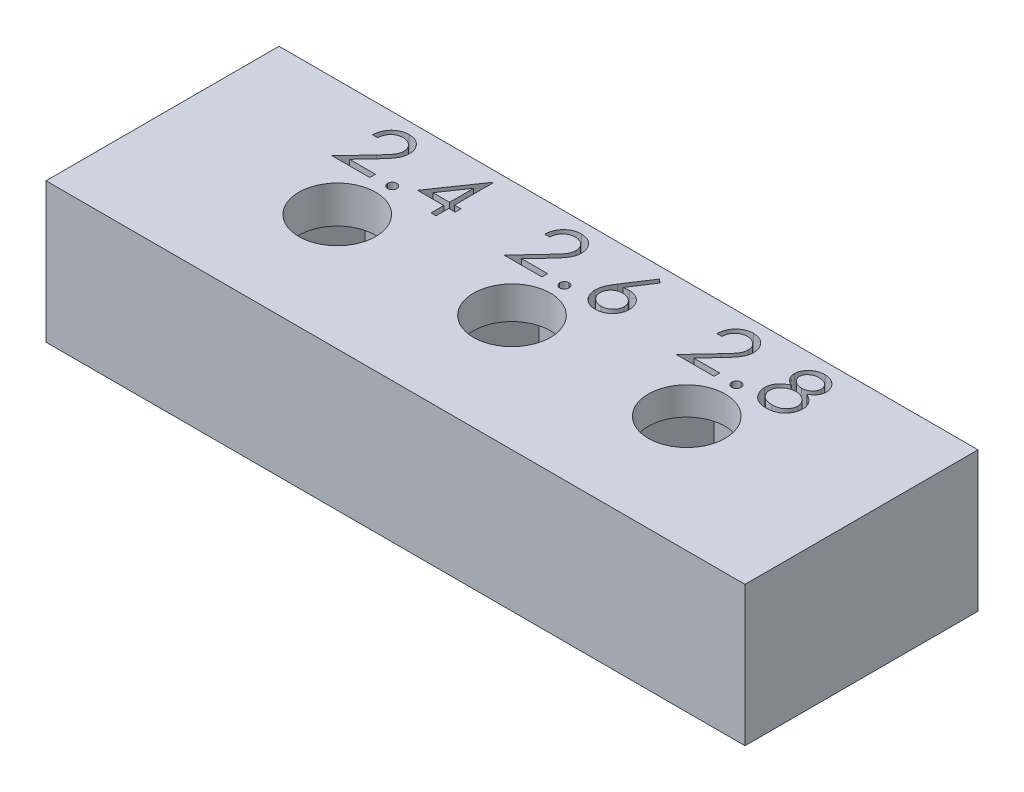
from build123d import *

# Parameters (mm, degrees)
SKETCH1_W           = 30
SKETCH1_H           = 10
SKETCH1_R           = 1.65
BOSS_EXTRUDE1_DEPTH = 6
CUT_EXTRUDE1_START  = 2
CUT_EXTRUDE1_DEPTH  = 2.4
CUT_EXTRUDE2_START  = 2
CUT_EXTRUDE2_DEPTH  = 2.6
CUT_EXTRUDE3_START  = 2
CUT_EXTRUDE3_DEPTH  = 2.8
CUT_EXTRUDE4_DEPTH  = 1


with BuildPart() as part:
    # Sketch1 → Boss-Extrude1 (new body)
    with BuildSketch(Plane(origin=(0, 0, 0), x_dir=(1, 0, 0), z_dir=(0, 1, 0))):
        with Locations((15, 5)):
            Rectangle(SKETCH1_W, SKETCH1_H)
        with Locations(Location((7.5, 5, 0), (0, 0, 270))):
            Circle(SKETCH1_R, mode=Mode.SUBTRACT)
        with Locations(Location((15, 5, 0), (0, 0, 270))):
            Circle(SKETCH1_R, mode=Mode.SUBTRACT)
        with Locations(Location((22.5, 5, 0), (0, 0, 270))):
            Circle(SKETCH1_R, mode=Mode.SUBTRACT)
    extrude(amount=BOSS_EXTRUDE1_DEPTH)

    # Sketch2 → Cut-Extrude1 (cut)
    with BuildSketch(Plane(origin=(0, 0, 0), x_dir=(1, 0, 0), z_dir=(0, 1, 0)).offset(CUT_EXTRUDE1_START)):
        Polygon((10.733161507, 5), (9.116580754, 7.8), (5.883419246, 7.8), (4.266838493, 5), (5.883419246, 2.2), (9.116580754, 2.2), align=None)
    extrude(amount=CUT_EXTRUDE1_DEPTH, mode=Mode.SUBTRACT)

    # Sketch3 → Cut-Extrude2 (cut)
    with BuildSketch(Plane(origin=(0, 0, 0), x_dir=(1, 0, 0), z_dir=(0, 1, 0)).offset(CUT_EXTRUDE2_START)):
        Polygon((18.175426481, 5), (16.58771324, 7.75), (13.41228676, 7.75), (11.824573519, 5), (13.41228676, 2.25), (16.58771324, 2.25), align=None)
    extrude(amount=CUT_EXTRUDE2_DEPTH, mode=Mode.SUBTRACT)

    # Sketch4 → Cut-Extrude3 (cut)
    with BuildSketch(Plane(origin=(0, 0, 0), x_dir=(1, 0, 0), z_dir=(0, 1, 0)).offset(CUT_EXTRUDE3_START)):
        Polygon((25.675426481, 5), (24.08771324, 7.75), (20.91228676, 7.75), (19.324573519, 5), (20.91228676, 2.25), (24.08771324, 2.25), align=None)
    extrude(amount=CUT_EXTRUDE3_DEPTH, mode=Mode.SUBTRACT)

    # Sketch5 → Cut-Extrude4 (cut)
    with BuildSketch(Plane(origin=(0, 6, 0), x_dir=(1, 0, 0), z_dir=(0, 1, 0))):
        with BuildLine():
            Line((5.513180713, 8.716214806), (5.29947879, 8.716214806))
            add(Edge.make_bspline(
                [(5.29947879, 8.716214806), (5.300871585, 8.744565892), (5.303606997, 8.800246671), (5.316416958, 8.881429543), (5.334746377, 8.95902754), (5.36066217, 9.032417606), (5.392847334, 9.102248652), (5.431444013, 9.168243305), (5.477159829, 9.23014981), (5.529007625, 9.287394274), (5.58531986, 9.339909389), (5.646079793, 9.385258759), (5.709927928, 9.423574889), (5.776670555, 9.455606948), (5.847060688, 9.479650665), (5.920459561, 9.497490745), (5.997189652, 9.508224294), (6.04946831, 9.509378034), (6.076056314, 9.509964806)],
                knots=[0, 0, 0, 0, 1.10065271, 2.161652631, 3.183658789, 4.190468796, 5.17591951, 6.163126047, 7.15150782, 8.156236427, 9.156009102, 10.134482811, 11.092018607, 12.041330605, 13.001268258, 13.972401359, 14.968799086, 16, 16, 16, 16], degree=3))
            add(Edge.make_bspline(
                [(6.076056314, 9.509964806), (6.10216711, 9.509353535), (6.153473893, 9.508152408), (6.228355371, 9.497837494), (6.299641352, 9.481682011), (6.367192493, 9.459015629), (6.430469833, 9.428546224), (6.489948726, 9.391944685), (6.546337278, 9.349612978), (6.597096536, 9.299774223), (6.643706497, 9.246568672), (6.683917138, 9.18976708), (6.718352166, 9.13110037), (6.747054855, 9.070121183), (6.768184121, 9.006255358), (6.784225723, 8.940432708), (6.793293124, 8.871971899), (6.794684743, 8.825635117), (6.795392251, 8.802077186)],
                knots=[0, 0, 0, 0, 1.111607364, 2.184268762, 3.212621178, 4.221274766, 5.211760367, 6.196651075, 7.1921475, 8.207485113, 9.220403448, 10.201281604, 11.166441695, 12.114753415, 13.065576456, 14.026450734, 14.996634279, 16, 16, 16, 16], degree=3))
            add(Edge.make_bspline(
                [(6.795392251, 8.802077186), (6.794240228, 8.768911248), (6.791956397, 8.703161389), (6.772420366, 8.606540562), (6.741908722, 8.512927897), (6.705171234, 8.437586982), (6.668110518, 8.376876337), (6.634713481, 8.326891379), (6.595616887, 8.273071409), (6.550251694, 8.215596649), (6.49955633, 8.154016908), (6.443071608, 8.088369387), (6.380394739, 8.019332343), (6.336403866, 7.972179782), (6.313608898, 7.947746507)],
                knots=[0, 0, 0, 0, 1.184426356, 2.348067706, 3.509069118, 4.696110526, 5.333549288, 6.050745305, 6.844228056, 7.710549037, 8.667450064, 9.695053472, 10.805634456, 12, 12, 12, 12], degree=3))
            Line((6.313608898, 7.947746507), (5.717819385, 7.311887883))
            Line((5.717819385, 7.311887883), (6.825921097, 7.311887883))
            Line((6.825921097, 7.311887883), (6.825921097, 7.067657114))
            Line((6.825921097, 7.067657114), (5.207892251, 7.067657114))
            Line((5.207892251, 7.067657114), (6.131389847, 8.053166428))
            add(Edge.make_bspline(
                [(6.131389847, 8.053166428), (6.153874213, 8.076637598), (6.197062078, 8.12172091), (6.258146296, 8.187540674), (6.313009607, 8.248602415), (6.362007155, 8.304790764), (6.404076022, 8.356927598), (6.441408737, 8.403324352), (6.471321041, 8.44601979), (6.503784551, 8.495509387), (6.535226564, 8.555933481), (6.562245149, 8.629775152), (6.578719894, 8.705789586), (6.580696219, 8.757157936), (6.581690328, 8.782996657)],
                knots=[0, 0, 0, 0, 1.329631726, 2.553950428, 3.673215718, 4.687767853, 5.603093632, 6.413772471, 7.123043292, 7.734684054, 8.834405432, 9.900288307, 10.943827018, 12, 12, 12, 12], degree=3))
            add(Edge.make_bspline(
                [(6.581690328, 8.782996657), (6.581257796, 8.799244537), (6.580405359, 8.831265988), (6.572882176, 8.878214549), (6.561513063, 8.923502396), (6.545221736, 8.967268831), (6.523717865, 9.00907382), (6.497542226, 9.048968248), (6.467341129, 9.08753699), (6.432403926, 9.123700216), (6.394023946, 9.156820822), (6.353478572, 9.186160602), (6.310581984, 9.210680068), (6.265515043, 9.230780198), (6.218403394, 9.246547734), (6.169155915, 9.257473303), (6.117908683, 9.264332993), (6.082915537, 9.265261117), (6.06508501, 9.265734037)],
                knots=[0, 0, 0, 0, 0.991446411, 1.95395049, 2.89581595, 3.838931463, 4.798493298, 5.75982156, 6.748411868, 7.785213223, 8.824556874, 9.840280684, 10.836137867, 11.835679398, 12.848801643, 13.863922112, 14.911575587, 16, 16, 16, 16], degree=3))
            add(Edge.make_bspline(
                [(6.06508501, 9.265734037), (6.046463068, 9.265247559), (6.009892649, 9.264292198), (5.956199522, 9.257609279), (5.904978305, 9.246080055), (5.856100153, 9.230311639), (5.809482364, 9.210269305), (5.765351648, 9.185305814), (5.723807075, 9.155517402), (5.684770548, 9.121744095), (5.648804162, 9.084142388), (5.617203698, 9.042225609), (5.589592074, 8.9967591), (5.565501149, 8.94786554), (5.54593701, 8.895101271), (5.53098742, 8.838653601), (5.519158155, 8.778767625), (5.515206287, 8.737412059), (5.513180713, 8.716214806)],
                knots=[0, 0, 0, 0, 1.031018746, 2.02475058, 2.990194455, 3.934040569, 4.864654155, 5.795059489, 6.735614925, 7.690564532, 8.649604399, 9.611025574, 10.590972636, 11.591080095, 12.624614302, 13.701020113, 14.821632451, 16, 16, 16, 16], degree=3))
        make_face()
        with BuildLine():
            add(Edge.make_bspline(
                [(7.622723982, 7.434003267), (7.635984287, 7.4332153), (7.661979565, 7.431670583), (7.6995619, 7.421072882), (7.733576124, 7.402255115), (7.763873955, 7.37717526), (7.788847468, 7.346766247), (7.808335858, 7.313023316), (7.818841243, 7.275126339), (7.820374708, 7.248980436), (7.821161482, 7.235565767)],
                knots=[0, 0, 0, 0, 1.020151414, 1.999887582, 2.974338812, 3.990962822, 5.007586832, 5.987933904, 6.967670073, 8, 8, 8, 8], degree=3))
            add(Edge.make_bspline(
                [(7.821161482, 7.235565767), (7.820348046, 7.222473431), (7.818743963, 7.196655535), (7.808359939, 7.159044397), (7.788698944, 7.125280378), (7.764046208, 7.094458744), (7.733568634, 7.069325759), (7.699481485, 7.050668091), (7.66206779, 7.039311583), (7.635999006, 7.037864942), (7.622723982, 7.037128267)],
                knots=[0, 0, 0, 0, 1.009421747, 1.99056486, 2.972319754, 3.999869655, 5.017953583, 5.993804169, 6.978383603, 8, 8, 8, 8], degree=3))
            add(Edge.make_bspline(
                [(7.622723982, 7.037128267), (7.609439392, 7.037838286), (7.583504394, 7.039224429), (7.546230352, 7.050901267), (7.511935611, 7.069150799), (7.481463971, 7.094505608), (7.456604761, 7.125121777), (7.437809634, 7.159276927), (7.426522408, 7.19654787), (7.425037955, 7.222452225), (7.424286482, 7.235565767)],
                knots=[0, 0, 0, 0, 1.022052826, 1.995314843, 2.982371812, 4.00089066, 5.028879526, 6.005146991, 6.990147033, 8, 8, 8, 8], degree=3))
            add(Edge.make_bspline(
                [(7.424286482, 7.235565767), (7.425009089, 7.249002399), (7.42641989, 7.275235773), (7.43783333, 7.31279088), (7.456458931, 7.346923336), (7.481635816, 7.377128866), (7.511928239, 7.402429513), (7.546147621, 7.420843239), (7.583594166, 7.431756448), (7.609454499, 7.433241339), (7.622723982, 7.434003267)],
                knots=[0, 0, 0, 0, 1.032775665, 2.016367738, 2.991239715, 4.008302682, 5.025365648, 6.011011707, 6.979408107, 8, 8, 8, 8], degree=3))
        make_face()
        Polygon((9.627801356, 9.509964806), (9.671209559, 9.509964806), (9.671209559, 7.861407114), (9.945969174, 7.861407114), (9.945969174, 7.617176344), (9.671209559, 7.617176344), (9.671209559, 7.067657114), (9.457507636, 7.067657114), (9.457507636, 7.617176344), (8.327940328, 7.617176344), align=None)
        Polygon((9.457507636, 7.861407114), (9.457507636, 8.895571777), (8.747711963, 7.861407114), align=None, mode=Mode.SUBTRACT)
        with BuildLine():
            Line((12.901161482, 8.716214806), (12.687459559, 8.716214806))
            add(Edge.make_bspline(
                [(12.687459559, 8.716214806), (12.688852354, 8.744565892), (12.691587767, 8.800246671), (12.704397728, 8.881429543), (12.722727146, 8.95902754), (12.748642939, 9.032417606), (12.780828103, 9.102248652), (12.819424782, 9.168243305), (12.865140598, 9.23014981), (12.916988394, 9.287394274), (12.973300629, 9.339909389), (13.034060563, 9.385258759), (13.097908697, 9.423574889), (13.164651324, 9.455606948), (13.235041458, 9.479650665), (13.30844033, 9.497490745), (13.385170421, 9.508224294), (13.437449079, 9.509378034), (13.464037083, 9.509964806)],
                knots=[0, 0, 0, 0, 1.10065271, 2.161652631, 3.183658789, 4.190468796, 5.17591951, 6.163126047, 7.15150782, 8.156236427, 9.156009102, 10.134482811, 11.092018607, 12.041330605, 13.001268258, 13.972401359, 14.968799086, 16, 16, 16, 16], degree=3))
            add(Edge.make_bspline(
                [(13.464037083, 9.509964806), (13.49014788, 9.509353535), (13.541454663, 9.508152408), (13.61633614, 9.497837494), (13.687622121, 9.481682011), (13.755173262, 9.459015629), (13.818450603, 9.428546224), (13.877929495, 9.391944685), (13.934318047, 9.349612978), (13.985077305, 9.299774223), (14.031687266, 9.246568672), (14.071897908, 9.18976708), (14.106332935, 9.13110037), (14.135035624, 9.070121183), (14.15616489, 9.006255358), (14.172206493, 8.940432708), (14.181273894, 8.871971899), (14.182665512, 8.825635117), (14.18337302, 8.802077186)],
                knots=[0, 0, 0, 0, 1.111607364, 2.184268762, 3.212621178, 4.221274766, 5.211760367, 6.196651075, 7.1921475, 8.207485113, 9.220403448, 10.201281604, 11.166441695, 12.114753415, 13.065576456, 14.026450734, 14.996634279, 16, 16, 16, 16], degree=3))
            add(Edge.make_bspline(
                [(14.18337302, 8.802077186), (14.182220997, 8.768911248), (14.179937166, 8.703161389), (14.160401135, 8.606540562), (14.129889491, 8.512927897), (14.093152003, 8.437586982), (14.056091287, 8.376876337), (14.022694251, 8.326891379), (13.983597656, 8.273071409), (13.938232464, 8.215596649), (13.887537099, 8.154016908), (13.831052377, 8.088369387), (13.768375508, 8.019332343), (13.724384635, 7.972179782), (13.701589667, 7.947746507)],
                knots=[0, 0, 0, 0, 1.184426356, 2.348067706, 3.509069118, 4.696110526, 5.333549288, 6.050745305, 6.844228056, 7.710549037, 8.667450064, 9.695053472, 10.805634456, 12, 12, 12, 12], degree=3))
            Line((13.701589667, 7.947746507), (13.105800154, 7.311887883))
            Line((13.105800154, 7.311887883), (14.213901866, 7.311887883))
            Line((14.213901866, 7.311887883), (14.213901866, 7.067657114))
            Line((14.213901866, 7.067657114), (12.59587302, 7.067657114))
            Line((12.59587302, 7.067657114), (13.519370616, 8.053166428))
            add(Edge.make_bspline(
                [(13.519370616, 8.053166428), (13.541854982, 8.076637598), (13.585042848, 8.12172091), (13.646127065, 8.187540674), (13.700990377, 8.248602415), (13.749987924, 8.304790764), (13.792056791, 8.356927598), (13.829389506, 8.403324352), (13.85930181, 8.44601979), (13.89176532, 8.495509387), (13.923207333, 8.555933481), (13.950225918, 8.629775152), (13.966700663, 8.705789586), (13.968676989, 8.757157936), (13.969671097, 8.782996657)],
                knots=[0, 0, 0, 0, 1.329631726, 2.553950428, 3.673215718, 4.687767853, 5.603093632, 6.413772471, 7.123043292, 7.734684054, 8.834405432, 9.900288307, 10.943827018, 12, 12, 12, 12], degree=3))
            add(Edge.make_bspline(
                [(13.969671097, 8.782996657), (13.969238565, 8.799244537), (13.968386128, 8.831265988), (13.960862945, 8.878214549), (13.949493833, 8.923502396), (13.933202505, 8.967268831), (13.911698634, 9.00907382), (13.885522995, 9.048968248), (13.855321898, 9.08753699), (13.820384695, 9.123700216), (13.782004715, 9.156820822), (13.741459342, 9.186160602), (13.698562753, 9.210680068), (13.653495813, 9.230780198), (13.606384163, 9.246547734), (13.557136684, 9.257473303), (13.505889452, 9.264332993), (13.470896306, 9.265261117), (13.453065779, 9.265734037)],
                knots=[0, 0, 0, 0, 0.991446411, 1.95395049, 2.89581595, 3.838931463, 4.798493298, 5.75982156, 6.748411868, 7.785213223, 8.824556874, 9.840280684, 10.836137867, 11.835679398, 12.848801643, 13.863922112, 14.911575587, 16, 16, 16, 16], degree=3))
            add(Edge.make_bspline(
                [(13.453065779, 9.265734037), (13.434443837, 9.265247559), (13.397873419, 9.264292198), (13.344180291, 9.257609279), (13.292959074, 9.246080055), (13.244080923, 9.230311639), (13.197463133, 9.210269305), (13.153332417, 9.185305814), (13.111787844, 9.155517402), (13.072751317, 9.121744095), (13.036784931, 9.084142388), (13.005184467, 9.042225609), (12.977572843, 8.9967591), (12.953481919, 8.94786554), (12.933917779, 8.895101271), (12.91896819, 8.838653601), (12.907138924, 8.778767625), (12.903187056, 8.737412059), (12.901161482, 8.716214806)],
                knots=[0, 0, 0, 0, 1.031018746, 2.02475058, 2.990194455, 3.934040569, 4.864654155, 5.795059489, 6.735614925, 7.690564532, 8.649604399, 9.611025574, 10.590972636, 11.591080095, 12.624614302, 13.701020113, 14.821632451, 16, 16, 16, 16], degree=3))
        make_face()
        with BuildLine():
            add(Edge.make_bspline(
                [(15.010704751, 7.434003267), (15.023965056, 7.4332153), (15.049960334, 7.431670583), (15.08754267, 7.421072882), (15.121556893, 7.402255115), (15.151854724, 7.37717526), (15.176828238, 7.346766247), (15.196316627, 7.313023316), (15.206822012, 7.275126339), (15.208355477, 7.248980436), (15.209142251, 7.235565767)],
                knots=[0, 0, 0, 0, 1.020151414, 1.999887582, 2.974338812, 3.990962822, 5.007586832, 5.987933904, 6.967670073, 8, 8, 8, 8], degree=3))
            add(Edge.make_bspline(
                [(15.209142251, 7.235565767), (15.208328816, 7.222473431), (15.206724733, 7.196655535), (15.196340708, 7.159044397), (15.176679713, 7.125280378), (15.152026977, 7.094458744), (15.121549404, 7.069325759), (15.087462254, 7.050668091), (15.050048559, 7.039311583), (15.023979775, 7.037864942), (15.010704751, 7.037128267)],
                knots=[0, 0, 0, 0, 1.009421747, 1.99056486, 2.972319754, 3.999869655, 5.017953583, 5.993804169, 6.978383603, 8, 8, 8, 8], degree=3))
            add(Edge.make_bspline(
                [(15.010704751, 7.037128267), (14.997420162, 7.037838286), (14.971485163, 7.039224429), (14.934211121, 7.050901267), (14.89991638, 7.069150799), (14.86944474, 7.094505608), (14.84458553, 7.125121777), (14.825790403, 7.159276927), (14.814503177, 7.19654787), (14.813018724, 7.222452225), (14.812267251, 7.235565767)],
                knots=[0, 0, 0, 0, 1.022052826, 1.995314843, 2.982371812, 4.00089066, 5.028879526, 6.005146991, 6.990147033, 8, 8, 8, 8], degree=3))
            add(Edge.make_bspline(
                [(14.812267251, 7.235565767), (14.812989858, 7.249002399), (14.814400659, 7.275235773), (14.825814099, 7.31279088), (14.844439701, 7.346923336), (14.869616585, 7.377128866), (14.899909008, 7.402429513), (14.934128391, 7.420843239), (14.971574935, 7.431756448), (14.997435268, 7.433241339), (15.010704751, 7.434003267)],
                knots=[0, 0, 0, 0, 1.032775665, 2.016367738, 2.991239715, 4.008302682, 5.025365648, 6.011011707, 6.979408107, 8, 8, 8, 8], degree=3))
        make_face()
        with BuildLine():
            Line((16.814959559, 9.509964806), (16.97952912, 9.380694223))
            Line((16.97952912, 9.380694223), (16.350348681, 8.418558556))
            add(Edge.make_bspline(
                [(16.350348681, 8.418558556), (16.392238459, 8.425235486), (16.473949207, 8.438259593), (16.556657434, 8.440408124), (16.596964517, 8.44145519)],
                knots=[0, 0, 0, 0, 1.025318673, 2, 2, 2, 2], degree=3))
            add(Edge.make_bspline(
                [(16.596964517, 8.44145519), (16.621166519, 8.440804693), (16.668807439, 8.439524208), (16.738752782, 8.429670017), (16.80596454, 8.414140789), (16.870164137, 8.391503772), (16.931582005, 8.362586992), (16.990570599, 8.327930367), (17.046021074, 8.28574436), (17.098647501, 8.238619452), (17.146427009, 8.186424504), (17.188728932, 8.131042523), (17.224261803, 8.07253121), (17.253091203, 8.010920199), (17.275478272, 7.946304463), (17.291798438, 7.878766676), (17.301445625, 7.808260264), (17.302755647, 7.760309934), (17.303421097, 7.735952636)],
                knots=[0, 0, 0, 0, 1.04369286, 2.054478336, 3.041073146, 4.015093852, 4.984733326, 5.965804835, 6.960378782, 7.985147595, 9.009457201, 10.008161701, 10.986880575, 11.956520048, 12.937015923, 13.931873656, 14.949455224, 16, 16, 16, 16], degree=3))
            add(Edge.make_bspline(
                [(17.303421097, 7.735952636), (17.302452878, 7.702628945), (17.300547651, 7.637055806), (17.281563104, 7.541549512), (17.25206306, 7.450563639), (17.209896206, 7.365550857), (17.157520691, 7.28662768), (17.093650401, 7.216696854), (17.020550456, 7.15432849), (16.937896045, 7.102174611), (16.848944136, 7.059582178), (16.755495723, 7.028989755), (16.658458325, 7.010155109), (16.592596619, 7.007793859), (16.559280472, 7.006599421)],
                knots=[0, 0, 0, 0, 1.031375318, 2.029502543, 3.004789286, 3.987476834, 4.960371455, 5.9300674, 6.912260825, 7.929083631, 8.949397511, 9.960523116, 10.96833055, 12, 12, 12, 12], degree=3))
            add(Edge.make_bspline(
                [(16.559280472, 7.006599421), (16.527237896, 7.007639147), (16.463767161, 7.009698661), (16.37039985, 7.02804513), (16.280685904, 7.057781569), (16.195253879, 7.098748784), (16.116114319, 7.150495308), (16.04531252, 7.212790359), (15.983201509, 7.284302334), (15.931511633, 7.365020142), (15.890514174, 7.451758845), (15.859768886, 7.542203589), (15.841810013, 7.636024826), (15.839300477, 7.699625387), (15.838036482, 7.731659517)],
                knots=[0, 0, 0, 0, 1.012016664, 2.004627821, 2.994792927, 3.992885782, 4.990978636, 5.973936114, 6.964471063, 7.975201453, 8.993600317, 9.990122807, 10.98767138, 12, 12, 12, 12], degree=3))
            add(Edge.make_bspline(
                [(15.838036482, 7.731659517), (15.838840286, 7.756182707), (15.840481502, 7.806254375), (15.851941023, 7.882089722), (15.870354749, 7.95968519), (15.890976542, 8.025512597), (15.912765394, 8.07943874), (15.93089864, 8.122915936), (15.953468805, 8.167656952), (15.977535338, 8.215195979), (16.005264565, 8.264307854), (16.035415033, 8.315813386), (16.068820331, 8.368893441), (16.092238335, 8.404914402), (16.104209859, 8.423328688)],
                knots=[0, 0, 0, 0, 1.173818275, 2.396712641, 3.66331629, 4.989737886, 5.693666774, 6.447286557, 7.243889047, 8.091586357, 8.998013824, 9.943181721, 10.948533338, 12, 12, 12, 12], degree=3))
            Line((16.104209859, 8.423328688), (16.814959559, 9.509964806))
        make_face()
        with BuildLine():
            add(Edge.make_bspline(
                [(16.552125274, 8.197224421), (16.533985425, 8.196695074), (16.498553031, 8.195661104), (16.446568701, 8.189656781), (16.397369864, 8.178349881), (16.350304707, 8.163949216), (16.306253144, 8.144148741), (16.264895023, 8.120096892), (16.226070407, 8.091779626), (16.190185955, 8.059598114), (16.157651506, 8.024363756), (16.129633629, 7.98662467), (16.105465711, 7.947290364), (16.085815759, 7.906032185), (16.070514475, 7.862865906), (16.059446254, 7.81799006), (16.05328647, 7.771103719), (16.052261695, 7.739308927), (16.051738405, 7.723073279)],
                knots=[0, 0, 0, 0, 1.129588631, 2.206414736, 3.251139165, 4.268635594, 5.265702196, 6.250456724, 7.242448911, 8.251968645, 9.246821453, 10.222880186, 11.173611482, 12.116736599, 13.062300278, 14.020270554, 14.989073742, 16, 16, 16, 16], degree=3))
            add(Edge.make_bspline(
                [(16.051738405, 7.723073279), (16.052164554, 7.706982847), (16.05300017, 7.675431903), (16.060587731, 7.628936854), (16.072177671, 7.584193229), (16.08941819, 7.541431695), (16.109983269, 7.50000045), (16.137133142, 7.461400193), (16.167216348, 7.423286539), (16.203175899, 7.388587323), (16.241768044, 7.35629987), (16.282998505, 7.328078483), (16.325969835, 7.303935212), (16.371262177, 7.285013733), (16.418232935, 7.269485066), (16.467273455, 7.258557524), (16.518417844, 7.252379523), (16.553062948, 7.251353413), (16.57072879, 7.25083019)],
                knots=[0, 0, 0, 0, 0.989467248, 1.94019797, 2.891935182, 3.827694429, 4.772920941, 5.730924762, 6.725747692, 7.756678648, 8.79901574, 9.819492441, 10.826891316, 11.826466727, 12.835195252, 13.867842842, 14.912794438, 16, 16, 16, 16], degree=3))
            add(Edge.make_bspline(
                [(16.57072879, 7.25083019), (16.588394602, 7.251353454), (16.623039649, 7.252379645), (16.67418445, 7.258557062), (16.723223449, 7.26948676), (16.770199734, 7.285007592), (16.815471672, 7.303957994), (16.85840542, 7.327928282), (16.899245962, 7.356473426), (16.937863442, 7.388532146), (16.973673318, 7.423484033), (17.004478038, 7.461059969), (17.030796452, 7.500312423), (17.052182926, 7.541268487), (17.069233554, 7.584219085), (17.080882267, 7.628929928), (17.088454158, 7.675433717), (17.089291927, 7.706983459), (17.089719174, 7.723073279)],
                knots=[0, 0, 0, 0, 1.087397944, 2.132534446, 3.165364764, 4.174271784, 5.174024072, 6.181601208, 7.194203697, 8.236725232, 9.267838612, 10.269026844, 11.221737037, 12.171628256, 13.107553087, 14.05945871, 15.010357665, 16, 16, 16, 16], degree=3))
            add(Edge.make_bspline(
                [(17.089719174, 7.723073279), (17.089344778, 7.739330108), (17.088609961, 7.771236975), (17.080298753, 7.817969087), (17.068771888, 7.863093914), (17.051366291, 7.906327855), (17.02875357, 7.947500298), (17.001210395, 7.986819227), (16.969347521, 8.024586088), (16.932541874, 8.059667213), (16.892475482, 8.091744064), (16.849874522, 8.120060227), (16.805305704, 8.143957755), (16.758814218, 8.163897052), (16.709867364, 8.178286247), (16.659255365, 8.1896164), (16.606330898, 8.195645737), (16.570423956, 8.196691491), (16.552125274, 8.197224421)],
                knots=[0, 0, 0, 0, 0.978206639, 1.919901502, 2.851605144, 3.780102724, 4.718870031, 5.675451981, 6.667674623, 7.690630536, 8.733308323, 9.756129687, 10.767539656, 11.776269907, 12.797430371, 13.836405707, 14.897401972, 16, 16, 16, 16], degree=3))
        make_face(mode=Mode.SUBTRACT)
        with BuildLine():
            Line((20.289142251, 8.716214806), (20.075440328, 8.716214806))
            add(Edge.make_bspline(
                [(20.075440328, 8.716214806), (20.076833123, 8.744565892), (20.079568536, 8.800246671), (20.092378497, 8.881429543), (20.110707915, 8.95902754), (20.136623708, 9.032417606), (20.168808872, 9.102248652), (20.207405551, 9.168243305), (20.253121367, 9.23014981), (20.304969163, 9.287394274), (20.361281398, 9.339909389), (20.422041332, 9.385258759), (20.485889467, 9.423574889), (20.552632093, 9.455606948), (20.623022227, 9.479650665), (20.6964211, 9.497490745), (20.773151191, 9.508224294), (20.825429849, 9.509378034), (20.852017852, 9.509964806)],
                knots=[0, 0, 0, 0, 1.10065271, 2.161652631, 3.183658789, 4.190468796, 5.17591951, 6.163126047, 7.15150782, 8.156236427, 9.156009102, 10.134482811, 11.092018607, 12.041330605, 13.001268258, 13.972401359, 14.968799086, 16, 16, 16, 16], degree=3))
            add(Edge.make_bspline(
                [(20.852017852, 9.509964806), (20.878128649, 9.509353535), (20.929435432, 9.508152408), (21.00431691, 9.497837494), (21.07560289, 9.481682011), (21.143154031, 9.459015629), (21.206431372, 9.428546224), (21.265910265, 9.391944685), (21.322298816, 9.349612978), (21.373058074, 9.299774223), (21.419668035, 9.246568672), (21.459878677, 9.18976708), (21.494313704, 9.13110037), (21.523016394, 9.070121183), (21.54414566, 9.006255358), (21.560187262, 8.940432708), (21.569254663, 8.871971899), (21.570646281, 8.825635117), (21.57135379, 8.802077186)],
                knots=[0, 0, 0, 0, 1.111607364, 2.184268762, 3.212621178, 4.221274766, 5.211760367, 6.196651075, 7.1921475, 8.207485113, 9.220403448, 10.201281604, 11.166441695, 12.114753415, 13.065576456, 14.026450734, 14.996634279, 16, 16, 16, 16], degree=3))
            add(Edge.make_bspline(
                [(21.57135379, 8.802077186), (21.570201766, 8.768911248), (21.567917936, 8.703161389), (21.548381904, 8.606540562), (21.51787026, 8.512927897), (21.481132773, 8.437586982), (21.444072056, 8.376876337), (21.41067502, 8.326891379), (21.371578425, 8.273071409), (21.326213233, 8.215596649), (21.275517868, 8.154016908), (21.219033146, 8.088369387), (21.156356277, 8.019332343), (21.112365404, 7.972179782), (21.089570436, 7.947746507)],
                knots=[0, 0, 0, 0, 1.184426356, 2.348067706, 3.509069118, 4.696110526, 5.333549288, 6.050745305, 6.844228056, 7.710549037, 8.667450064, 9.695053472, 10.805634456, 12, 12, 12, 12], degree=3))
            Line((21.089570436, 7.947746507), (20.493780923, 7.311887883))
            Line((20.493780923, 7.311887883), (21.601882636, 7.311887883))
            Line((21.601882636, 7.311887883), (21.601882636, 7.067657114))
            Line((21.601882636, 7.067657114), (19.98385379, 7.067657114))
            Line((19.98385379, 7.067657114), (20.907351386, 8.053166428))
            add(Edge.make_bspline(
                [(20.907351386, 8.053166428), (20.929835752, 8.076637598), (20.973023617, 8.12172091), (21.034107834, 8.187540674), (21.088971146, 8.248602415), (21.137968694, 8.304790764), (21.180037561, 8.356927598), (21.217370275, 8.403324352), (21.247282579, 8.44601979), (21.27974609, 8.495509387), (21.311188102, 8.555933481), (21.338206687, 8.629775152), (21.354681432, 8.705789586), (21.356657758, 8.757157936), (21.357651866, 8.782996657)],
                knots=[0, 0, 0, 0, 1.329631726, 2.553950428, 3.673215718, 4.687767853, 5.603093632, 6.413772471, 7.123043292, 7.734684054, 8.834405432, 9.900288307, 10.943827018, 12, 12, 12, 12], degree=3))
            add(Edge.make_bspline(
                [(21.357651866, 8.782996657), (21.357219335, 8.799244537), (21.356366898, 8.831265988), (21.348843714, 8.878214549), (21.337474602, 8.923502396), (21.321183275, 8.967268831), (21.299679403, 9.00907382), (21.273503764, 9.048968248), (21.243302668, 9.08753699), (21.208365465, 9.123700216), (21.169985484, 9.156820822), (21.129440111, 9.186160602), (21.086543522, 9.210680068), (21.041476582, 9.230780198), (20.994364932, 9.246547734), (20.945117454, 9.257473303), (20.893870221, 9.264332993), (20.858877075, 9.265261117), (20.841046548, 9.265734037)],
                knots=[0, 0, 0, 0, 0.991446411, 1.95395049, 2.89581595, 3.838931463, 4.798493298, 5.75982156, 6.748411868, 7.785213223, 8.824556874, 9.840280684, 10.836137867, 11.835679398, 12.848801643, 13.863922112, 14.911575587, 16, 16, 16, 16], degree=3))
            add(Edge.make_bspline(
                [(20.841046548, 9.265734037), (20.822424606, 9.265247559), (20.785854188, 9.264292198), (20.73216106, 9.257609279), (20.680939844, 9.246080055), (20.632061692, 9.230311639), (20.585443902, 9.210269305), (20.541313187, 9.185305814), (20.499768614, 9.155517402), (20.460732086, 9.121744095), (20.4247657, 9.084142388), (20.393165237, 9.042225609), (20.365553613, 8.9967591), (20.341462688, 8.94786554), (20.321898549, 8.895101271), (20.306948959, 8.838653601), (20.295119693, 8.778767625), (20.291167825, 8.737412059), (20.289142251, 8.716214806)],
                knots=[0, 0, 0, 0, 1.031018746, 2.02475058, 2.990194455, 3.934040569, 4.864654155, 5.795059489, 6.735614925, 7.690564532, 8.649604399, 9.611025574, 10.590972636, 11.591080095, 12.624614302, 13.701020113, 14.821632451, 16, 16, 16, 16], degree=3))
        make_face()
        with BuildLine():
            add(Edge.make_bspline(
                [(22.39868552, 7.434003267), (22.411945825, 7.4332153), (22.437941103, 7.431670583), (22.475523439, 7.421072882), (22.509537663, 7.402255115), (22.539835493, 7.37717526), (22.564809007, 7.346766247), (22.584297396, 7.313023316), (22.594802781, 7.275126339), (22.596336246, 7.248980436), (22.59712302, 7.235565767)],
                knots=[0, 0, 0, 0, 1.020151414, 1.999887582, 2.974338812, 3.990962822, 5.007586832, 5.987933904, 6.967670073, 8, 8, 8, 8], degree=3))
            add(Edge.make_bspline(
                [(22.59712302, 7.235565767), (22.596309585, 7.222473431), (22.594705502, 7.196655535), (22.584321477, 7.159044397), (22.564660483, 7.125280378), (22.540007746, 7.094458744), (22.509530173, 7.069325759), (22.475443024, 7.050668091), (22.438029328, 7.039311583), (22.411960544, 7.037864942), (22.39868552, 7.037128267)],
                knots=[0, 0, 0, 0, 1.009421747, 1.99056486, 2.972319754, 3.999869655, 5.017953583, 5.993804169, 6.978383603, 8, 8, 8, 8], degree=3))
            add(Edge.make_bspline(
                [(22.39868552, 7.037128267), (22.385400931, 7.037838286), (22.359465933, 7.039224429), (22.32219189, 7.050901267), (22.287897149, 7.069150799), (22.257425509, 7.094505608), (22.232566299, 7.125121777), (22.213771173, 7.159276927), (22.202483946, 7.19654787), (22.200999494, 7.222452225), (22.20024802, 7.235565767)],
                knots=[0, 0, 0, 0, 1.022052826, 1.995314843, 2.982371812, 4.00089066, 5.028879526, 6.005146991, 6.990147033, 8, 8, 8, 8], degree=3))
            add(Edge.make_bspline(
                [(22.20024802, 7.235565767), (22.200970627, 7.249002399), (22.202381428, 7.275235773), (22.213794869, 7.31279088), (22.23242047, 7.346923336), (22.257597355, 7.377128866), (22.287889777, 7.402429513), (22.32210916, 7.420843239), (22.359555704, 7.431756448), (22.385416037, 7.433241339), (22.39868552, 7.434003267)],
                knots=[0, 0, 0, 0, 1.032775665, 2.016367738, 2.991239715, 4.008302682, 5.025365648, 6.011011707, 6.979408107, 8, 8, 8, 8], degree=3))
        make_face()
        with BuildLine():
            add(Edge.make_bspline(
                [(24.261612954, 8.394230882), (24.281104198, 8.384067737), (24.319118633, 8.36424621), (24.373259555, 8.332330093), (24.422738529, 8.298692579), (24.468928357, 8.264922468), (24.51101753, 8.229726469), (24.548535425, 8.192964625), (24.582408788, 8.155554545), (24.611954511, 8.116862743), (24.637942001, 8.076992012), (24.660402043, 8.035837703), (24.679599819, 7.993490006), (24.694814604, 7.949486663), (24.707348001, 7.904474056), (24.71597194, 7.857870965), (24.720609879, 7.809984476), (24.721486732, 7.777621042), (24.721930713, 7.761234337)],
                knots=[0, 0, 0, 0, 1.272397273, 2.481599622, 3.635517121, 4.734568067, 5.792894095, 6.808321871, 7.773003508, 8.711915296, 9.623354172, 10.525449501, 11.423591555, 12.311487226, 13.218079475, 14.126165749, 15.051214107, 16, 16, 16, 16], degree=3))
            add(Edge.make_bspline(
                [(24.721930713, 7.761234337), (24.721405871, 7.738307844), (24.720367013, 7.692927712), (24.711318274, 7.625949197), (24.697770337, 7.560899038), (24.677985883, 7.497791497), (24.652327308, 7.436974798), (24.620706461, 7.378396883), (24.584912051, 7.321097674), (24.556165439, 7.285841974), (24.541619715, 7.268002666)],
                knots=[0, 0, 0, 0, 1.025265484, 2.029385089, 3.018602448, 3.995076438, 4.983346944, 5.966715145, 6.97116228, 8, 8, 8, 8], degree=3))
            add(Edge.make_bspline(
                [(24.541619715, 7.268002666), (24.522680971, 7.247187974), (24.485037514, 7.205815801), (24.420551272, 7.152101053), (24.34977924, 7.106959769), (24.272995268, 7.07017157), (24.190404604, 7.041538155), (24.102024847, 7.020962442), (24.007683701, 7.009177003), (23.942841942, 7.007473396), (23.909577197, 7.006599421)],
                knots=[0, 0, 0, 0, 0.954267603, 1.896743057, 2.838368354, 3.796610408, 4.779680527, 5.799409237, 6.871065594, 8, 8, 8, 8], degree=3))
            add(Edge.make_bspline(
                [(23.909577197, 7.006599421), (23.877591302, 7.007383518), (23.81535, 7.00890929), (23.724755087, 7.01924693), (23.64030707, 7.03736339), (23.561514931, 7.06215874), (23.488853677, 7.094414627), (23.422530352, 7.13456142), (23.361588061, 7.180983169), (23.307876263, 7.235013104), (23.26019109, 7.292882835), (23.218302825, 7.35258527), (23.183486176, 7.414125857), (23.154008277, 7.476586975), (23.131442176, 7.540844091), (23.115812868, 7.6065666), (23.105886924, 7.673639706), (23.104566259, 7.718904991), (23.103901866, 7.741676795)],
                knots=[0, 0, 0, 0, 1.256902934, 2.445805442, 3.576955095, 4.645999104, 5.686449165, 6.692658513, 7.68621702, 8.689161843, 9.678783111, 10.630372946, 11.551080876, 12.453998257, 13.34127905, 14.221779781, 15.105423033, 16, 16, 16, 16], degree=3))
            add(Edge.make_bspline(
                [(23.103901866, 7.741676795), (23.104295032, 7.758385817), (23.105072066, 7.791408741), (23.110450186, 7.840196695), (23.119096478, 7.887682994), (23.130839073, 7.934043036), (23.146753325, 7.978939308), (23.165968062, 8.022584541), (23.188373551, 8.065028009), (23.214282344, 8.106501819), (23.244423542, 8.146424844), (23.278552739, 8.185474619), (23.317352057, 8.223045211), (23.360389857, 8.259595646), (23.407174303, 8.2957743), (23.458920587, 8.329625965), (23.514256937, 8.363547188), (23.553585258, 8.383827495), (23.573759889, 8.394230882)],
                knots=[0, 0, 0, 0, 0.941657376, 1.861047343, 2.762797495, 3.66048619, 4.553285746, 5.444104102, 6.34607688, 7.256116206, 8.197091036, 9.162375105, 10.176350973, 11.237807142, 12.343728897, 13.50695164, 14.721116704, 16, 16, 16, 16], degree=3))
            add(Edge.make_bspline(
                [(23.573759889, 8.394230882), (23.546143258, 8.409290429), (23.492669729, 8.438449929), (23.421865341, 8.492025881), (23.361047792, 8.550052055), (23.311888779, 8.613753755), (23.273195352, 8.681141004), (23.246648766, 8.751792182), (23.228689729, 8.824397253), (23.226910713, 8.873999504), (23.226017251, 8.89891087)],
                knots=[0, 0, 0, 0, 1.166880483, 2.259407225, 3.286803203, 4.280235371, 5.237608625, 6.161067461, 7.076446754, 8, 8, 8, 8], degree=3))
            add(Edge.make_bspline(
                [(23.226017251, 8.89891087), (23.227129924, 8.92428653), (23.229366589, 8.975296032), (23.247452741, 9.051228056), (23.276925858, 9.125806469), (23.317013179, 9.198669802), (23.366942696, 9.267352001), (23.426845792, 9.328952181), (23.495291964, 9.382912314), (23.571939548, 9.428207889), (23.654423487, 9.465072128), (23.741451864, 9.490502805), (23.831508353, 9.507128092), (23.89280698, 9.509010405), (23.923887594, 9.509964806)],
                knots=[0, 0, 0, 0, 0.888701115, 1.786444228, 2.72001202, 3.692817113, 4.693886446, 5.687152267, 6.695133018, 7.739871481, 8.800368666, 9.853104506, 10.91144658, 12, 12, 12, 12], degree=3))
            add(Edge.make_bspline(
                [(23.923887594, 9.509964806), (23.954166082, 9.508980776), (24.013871812, 9.507040381), (24.101634228, 9.490856809), (24.185607225, 9.463826546), (24.265501223, 9.427157185), (24.33988594, 9.381990356), (24.405610011, 9.327289047), (24.463666643, 9.265960599), (24.51168924, 9.197299226), (24.551260777, 9.124715873), (24.578815855, 9.048772694), (24.596472465, 8.971110566), (24.598699522, 8.918561138), (24.599815328, 8.892232684)],
                knots=[0, 0, 0, 0, 1.072916533, 2.115669174, 3.151510826, 4.193348718, 5.225979165, 6.227137561, 7.216255879, 8.211077061, 9.189680878, 10.138522389, 11.067357538, 12, 12, 12, 12], degree=3))
            add(Edge.make_bspline(
                [(24.599815328, 8.892232684), (24.598839314, 8.86639499), (24.596922479, 8.815651226), (24.580798056, 8.741678362), (24.553642748, 8.67240301), (24.516567255, 8.607039091), (24.468244557, 8.546772036), (24.409319687, 8.490835474), (24.340262431, 8.438769899), (24.288377793, 8.409387748), (24.261612954, 8.394230882)],
                knots=[0, 0, 0, 0, 0.975232327, 1.915300861, 2.843280834, 3.77672583, 4.742871857, 5.749627742, 6.839139064, 8, 8, 8, 8], degree=3))
        make_face()
        with BuildLine():
            add(Edge.make_bspline(
                [(23.911962263, 9.265734037), (23.895258947, 9.265290824), (23.862579957, 9.264423707), (23.814663308, 9.259893456), (23.769098179, 9.251080643), (23.7254085, 9.239352162), (23.684193273, 9.223508013), (23.644892746, 9.204869623), (23.608175783, 9.182209603), (23.573599146, 9.156790645), (23.54247228, 9.128832793), (23.514846683, 9.099704174), (23.49189952, 9.068832702), (23.472413336, 9.0369863), (23.458274482, 9.003219783), (23.447685197, 8.968568393), (23.440526893, 8.932594248), (23.439990506, 8.908008515), (23.439719174, 8.895571777)],
                knots=[0, 0, 0, 0, 1.203892937, 2.355340988, 3.463153438, 4.544400666, 5.610487187, 6.640501085, 7.674077295, 8.714426146, 9.728707835, 10.68524104, 11.601827946, 12.495867327, 13.368432065, 14.231010473, 15.105153427, 16, 16, 16, 16], degree=3))
            add(Edge.make_bspline(
                [(23.439719174, 8.895571777), (23.440186829, 8.883134502), (23.441110983, 8.858556659), (23.448258221, 8.822262418), (23.458910474, 8.786596983), (23.475681728, 8.752408417), (23.495797411, 8.718510739), (23.520624648, 8.685751144), (23.550212718, 8.654015623), (23.583568887, 8.623574103), (23.619907809, 8.59506798), (23.658405167, 8.570321226), (23.698577801, 8.549615162), (23.740012959, 8.53238212), (23.783132938, 8.518985931), (23.827673521, 8.509482263), (23.873642193, 8.503575404), (23.904789338, 8.502869859), (23.920548501, 8.502512883)],
                knots=[0, 0, 0, 0, 0.873023192, 1.725219244, 2.590779336, 3.480155217, 4.391973325, 5.357036234, 6.360879153, 7.436073238, 8.526419356, 9.601555421, 10.645666583, 11.697338044, 12.750135903, 13.812665442, 14.89329948, 16, 16, 16, 16], degree=3))
            add(Edge.make_bspline(
                [(23.920548501, 8.502512883), (23.940789197, 8.503106744), (23.981070672, 8.504288601), (24.040451789, 8.515277168), (24.098188695, 8.532562265), (24.153664271, 8.556211457), (24.205442569, 8.585893983), (24.251598044, 8.62143109), (24.291737001, 8.662002213), (24.325442309, 8.70697575), (24.351574723, 8.754839955), (24.371918631, 8.802873369), (24.383798494, 8.851588458), (24.385348053, 8.884223124), (24.386113405, 8.900341909)],
                knots=[0, 0, 0, 0, 1.076279235, 2.141928126, 3.20205304, 4.278698113, 5.344010996, 6.36967002, 7.368914609, 8.37248503, 9.349703398, 10.264243087, 11.142681841, 12, 12, 12, 12], degree=3))
            add(Edge.make_bspline(
                [(24.386113405, 8.900341909), (24.385751525, 8.911654912), (24.385033244, 8.934109602), (24.379114099, 8.967269097), (24.369333398, 8.999674224), (24.356091553, 9.031592683), (24.338667746, 9.062576646), (24.318009254, 9.093113175), (24.29291462, 9.122515329), (24.264750261, 9.1514683), (24.232810617, 9.178263502), (24.197157241, 9.201827474), (24.157972921, 9.221838381), (24.115256732, 9.238091266), (24.069165989, 9.250298472), (24.01991298, 9.259439987), (23.967087026, 9.264592408), (23.930735713, 9.26534524), (23.911962263, 9.265734037)],
                knots=[0, 0, 0, 0, 0.814439003, 1.616544685, 2.417341072, 3.248991801, 4.09997495, 4.973547432, 5.9003056, 6.880240646, 7.880314356, 8.896779544, 9.951930927, 11.043077905, 12.18215768, 13.381699519, 14.647792085, 16, 16, 16, 16], degree=3))
        make_face(mode=Mode.SUBTRACT)
        with BuildLine():
            add(Edge.make_bspline(
                [(23.925795647, 8.258282114), (23.904618996, 8.25790544), (23.863075575, 8.257166497), (23.802212915, 8.248941319), (23.7438021, 8.237491322), (23.688040072, 8.220121233), (23.634950378, 8.197535764), (23.584245617, 8.170366015), (23.536313688, 8.138249454), (23.491816476, 8.101594114), (23.451183282, 8.06209295), (23.415533724, 8.020276747), (23.385259518, 7.976922667), (23.36088011, 7.931480096), (23.340869628, 7.884911276), (23.327729294, 7.836056465), (23.319305308, 7.785854876), (23.318174125, 7.751728094), (23.31760379, 7.734521597)],
                knots=[0, 0, 0, 0, 1.140299081, 2.23698856, 3.303958914, 4.344563908, 5.37730929, 6.408454204, 7.439741482, 8.480804886, 9.510774543, 10.48932336, 11.43758569, 12.353841022, 13.263987381, 14.161954604, 15.073269652, 16, 16, 16, 16], degree=3))
            add(Edge.make_bspline(
                [(23.31760379, 7.734521597), (23.318531292, 7.713137355), (23.320371436, 7.67071152), (23.334969614, 7.608007716), (23.358398076, 7.547305534), (23.391072375, 7.489099652), (23.431531563, 7.434705026), (23.481283678, 7.38729177), (23.537236819, 7.345163049), (23.60128418, 7.311090401), (23.671244262, 7.283879615), (23.747098456, 7.265131719), (23.827758142, 7.252721019), (23.8834519, 7.251470399), (23.911962263, 7.25083019)],
                knots=[0, 0, 0, 0, 0.898778495, 1.783155532, 2.693654817, 3.627872908, 4.583023416, 5.533784346, 6.509005473, 7.520592997, 8.575161974, 9.658835044, 10.801527049, 12, 12, 12, 12], degree=3))
            add(Edge.make_bspline(
                [(23.911962263, 7.25083019), (23.93424421, 7.251258005), (23.977656587, 7.252091524), (24.040988278, 7.259449107), (24.100753944, 7.271116976), (24.156837687, 7.288087496), (24.209867335, 7.308804355), (24.258943778, 7.33545536), (24.305329526, 7.365766852), (24.346738866, 7.401729276), (24.384453246, 7.440155504), (24.417337147, 7.480834086), (24.445883266, 7.522659472), (24.468288077, 7.566576855), (24.486199332, 7.611743667), (24.499074108, 7.658576399), (24.507018104, 7.707218691), (24.507821535, 7.74021538), (24.50822879, 7.756941218)],
                knots=[0, 0, 0, 0, 1.224942928, 2.386581632, 3.501229538, 4.569074225, 5.605009692, 6.626002462, 7.634866581, 8.645888296, 9.63523824, 10.59253846, 11.518950513, 12.414518923, 13.29783783, 14.186679152, 15.080837789, 16, 16, 16, 16], degree=3))
            add(Edge.make_bspline(
                [(24.50822879, 7.756941218), (24.507612489, 7.773186337), (24.506397252, 7.805218875), (24.498684253, 7.852685029), (24.485134344, 7.898543016), (24.466541954, 7.943344537), (24.441789906, 7.986181831), (24.412640093, 8.028170869), (24.37746963, 8.068146235), (24.337728203, 8.106418431), (24.294417375, 8.141807709), (24.248379549, 8.173113961), (24.199969103, 8.19947924), (24.149288475, 8.220921713), (24.096450201, 8.237786045), (24.041493142, 8.249567106), (23.984352957, 8.256982729), (23.945535268, 8.257844092), (23.925795647, 8.258282114)],
                knots=[0, 0, 0, 0, 0.917430815, 1.809013306, 2.70690318, 3.612392954, 4.541220862, 5.495268465, 6.494511384, 7.542276156, 8.608045339, 9.649016899, 10.681629292, 11.715607085, 12.752076957, 13.808767841, 14.885711793, 16, 16, 16, 16], degree=3))
        make_face(mode=Mode.SUBTRACT)
    extrude(amount=-CUT_EXTRUDE4_DEPTH, mode=Mode.SUBTRACT)


solid = part.part
